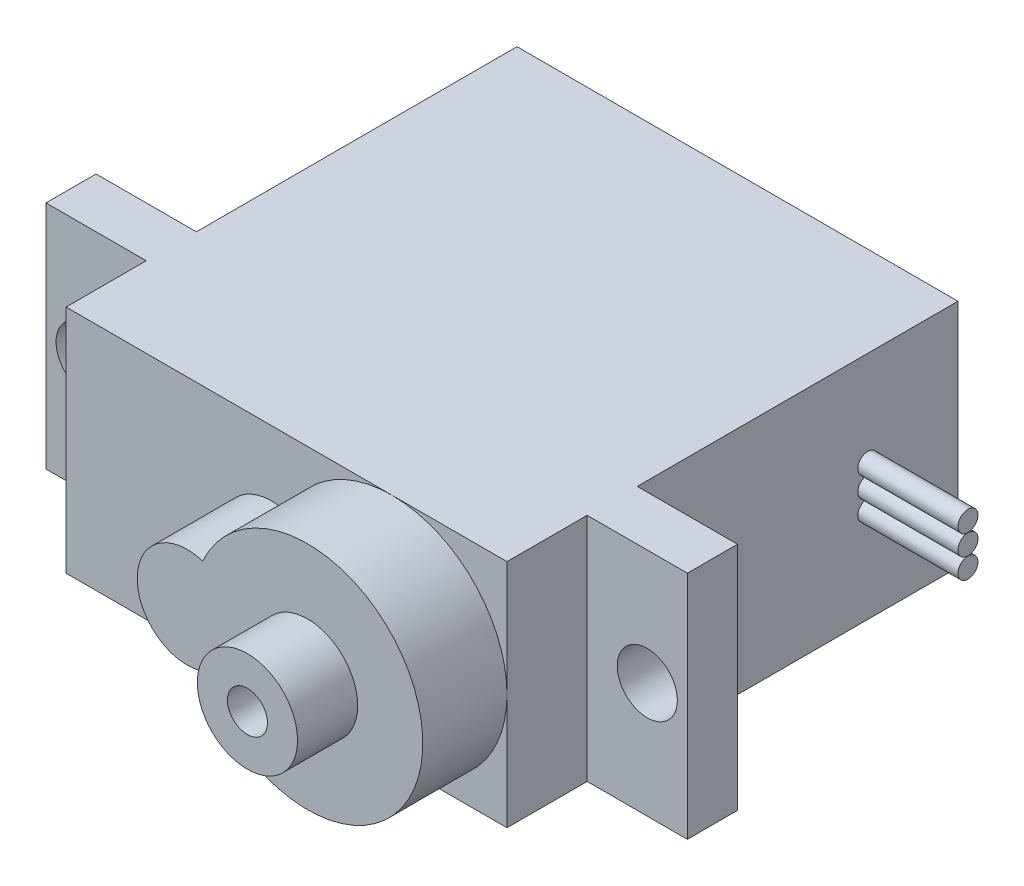
from build123d import *

# Parameters (mm, degrees)
SKETCH_1_W          = 22
SKETCH_1_H          = 11.5
EXTRUDE_1_DEPTH     = 16
SKETCH_2_W          = 32
SKETCH_2_H          = 11.5
EXTRUDE_2_DEPTH     = 2.5
SKETCH_3_W          = 22
SKETCH_3_H          = 11.5
EXTRUDE_3_DEPTH     = 4
EXTRUDE_4_DEPTH     = 4.2
SKETCH_5_R          = 1.5
CUT_EXTRUDE_1_DEPTH = 19.5
SKETCH_6_R          = 0.5
EXTRUDE_6_DEPTH     = 5
EXTRUDE_6_2_DEPTH   = 5
EXTRUDE_6_3_DEPTH   = 5
SKETCH_7_R          = 2.5
SKETCH_7_R_2        = 1
EXTRUDE_7_DEPTH     = 3
SKETCH_8_W          = 1.346153846
SKETCH_8_H          = 0.358974359
CUT_EXTRUDE_2_DEPTH = 2


with BuildPart() as part:
    # ｽｹｯﾁ1 → ﾎﾞｽ - 押し出し1 (new body)
    with BuildSketch(Plane.XY):
        with Locations((11, 5.75)):
            Rectangle(SKETCH_1_W, SKETCH_1_H)
    extrude(amount=EXTRUDE_1_DEPTH)

    # ｽｹｯﾁ2 → ﾎﾞｽ - 押し出し2 (add)
    with BuildSketch(Plane.XY.offset(16)):
        with Locations((11, 5.75)):
            Rectangle(SKETCH_2_W, SKETCH_2_H)
    extrude(amount=EXTRUDE_2_DEPTH)

    # ｽｹｯﾁ3 → ﾎﾞｽ - 押し出し3 (add)
    with BuildSketch(Plane.XY.offset(18.5)):
        with Locations((11, 5.75)):
            Rectangle(SKETCH_3_W, SKETCH_3_H)
    extrude(amount=EXTRUDE_3_DEPTH)

    # ｽｹｯﾁ4 → ﾎﾞｽ - 押し出し4 (add)
    with BuildSketch(Plane.XY.offset(22.5)):
        with BuildLine():
            ThreePointArc((11.015625, 8.129877803), (7.75, 5.75), (11.015625, 3.370122197))
            ThreePointArc((11.015625, 3.370122197), (22, 5.75), (11.015625, 8.129877803))
        make_face()
    extrude(amount=EXTRUDE_4_DEPTH)

    # ｽｹｯﾁ5 → ｶｯﾄ - 押し出し1 (cut, through all)
    with BuildSketch(Plane.XY.offset(18.5)):
        with Locations((-3, 5.75)):
            Circle(SKETCH_5_R)
        with Locations((25, 5.75)):
            Circle(SKETCH_5_R)
    extrude(amount=-CUT_EXTRUDE_1_DEPTH, mode=Mode.SUBTRACT)

    # ｽｹｯﾁ8 → ｶｯﾄ - 押し出し2 (cut)
    with BuildSketch(Plane.XZ):
        with BuildLine():
            Line((4.284609401, 12.059602692), (4.580482798, 12.236986506))
            add(Edge.make_bspline(
                [(4.580482798, 12.236986506), (4.608001035, 12.190922121), (4.660724916, 12.102664537), (4.748676275, 11.983406497), (4.839809186, 11.88204434), (4.93479852, 11.799167733), (5.033064468, 11.733918846), (5.135248522, 11.687716614), (5.241006332, 11.658900639), (5.312980154, 11.655400552), (5.348912285, 11.653653173)],
                knots=[0, 0, 0, 0, 0.000160901, 0.00030828, 0.000443778, 0.00056903, 0.000685513, 0.000796284, 0.00090427, 0.001011928, 0.001011928, 0.001011928, 0.001011928], degree=3))
            add(Edge.make_bspline(
                [(5.348912285, 11.653653173), (5.379599146, 11.654507845), (5.440435919, 11.656202236), (5.529998162, 11.672483038), (5.616979964, 11.697495167), (5.699588602, 11.733316098), (5.776684216, 11.776654584), (5.844290912, 11.829000761), (5.902737025, 11.887606967), (5.950546139, 11.952989622), (5.987226175, 12.02330677), (6.015418243, 12.095482722), (6.031063317, 12.17065129), (6.03342007, 12.221261753), (6.034609401, 12.246802211)],
                knots=[0, 0, 0, 0, 9.1978e-05, 0.000182347, 0.000272202, 0.000362975, 0.000451852, 0.000536835, 0.000618639, 0.000699414, 0.000778765, 0.000855983, 0.0009312, 0.001007828, 0.001007828, 0.001007828, 0.001007828], degree=3))
            add(Edge.make_bspline(
                [(6.034609401, 12.246802211), (6.03313509, 12.275943061), (6.030138032, 12.33518215), (6.004806552, 12.422581803), (5.964957305, 12.509074373), (5.928194661, 12.562575639), (5.909108599, 12.590351891)],
                knots=[0, 0, 0, 0, 8.7281e-05, 0.000177429, 0.000270909, 0.000371844, 0.000371844, 0.000371844, 0.000371844], degree=3))
            add(Edge.make_bspline(
                [(5.909108599, 12.590351891), (5.893437985, 12.610398715), (5.860539491, 12.652484513), (5.803981978, 12.715129749), (5.737615864, 12.779748168), (5.663712309, 12.848807224), (5.57957922, 12.919095021), (5.487851706, 12.993963299), (5.386187847, 13.070564876), (5.31488835, 13.121937442), (5.278098984, 13.14844484)],
                knots=[0, 0, 0, 0, 7.6319e-05, 0.000160223, 0.000252933, 0.000354147, 0.000463581, 0.000581729, 0.000709336, 0.000845369, 0.000845369, 0.000845369, 0.000845369], degree=3))
            add(Edge.make_bspline(
                [(5.278098984, 13.14844484), (5.241274988, 13.174673427), (5.170870311, 13.224820489), (5.072411729, 13.299244774), (4.984367266, 13.367288643), (4.907128249, 13.429592655), (4.840728653, 13.48616526), (4.784645242, 13.536463199), (4.740306684, 13.58184676), (4.715651104, 13.611288102), (4.704581356, 13.624506538)],
                knots=[0, 0, 0, 0, 0.000135623, 0.000259301, 0.000370234, 0.000469439, 0.00055697, 0.000631911, 0.000695377, 0.00074709, 0.00074709, 0.00074709, 0.00074709], degree=3))
            add(Edge.make_bspline(
                [(4.704581356, 13.624506538), (4.689108811, 13.645107575), (4.658679974, 13.685622279), (4.618513968, 13.748947137), (4.584374806, 13.813770402), (4.557612473, 13.880266267), (4.535076255, 13.947501196), (4.519918324, 14.016352441), (4.510426927, 14.08651106), (4.50945494, 14.13372456), (4.508968375, 14.157359102)],
                knots=[0, 0, 0, 0, 7.727e-05, 0.000151962, 0.000224716, 0.000296717, 0.00036678, 0.0004372, 0.000507902, 0.000578771, 0.000578771, 0.000578771, 0.000578771], degree=3))
            add(Edge.make_bspline(
                [(4.508968375, 14.157359102), (4.510273584, 14.194388877), (4.512856104, 14.267656941), (4.534696621, 14.374687771), (4.569169515, 14.476874188), (4.617464403, 14.573204522), (4.679721756, 14.661170503), (4.75176773, 14.74178399), (4.837579216, 14.809552572), (4.93173184, 14.868764631), (5.034788212, 14.915110556), (5.142779115, 14.950071536), (5.255876187, 14.969880794), (5.332479322, 14.972723559), (5.371348183, 14.974165993)],
                knots=[0, 0, 0, 0, 0.000110999, 0.000219625, 0.000326272, 0.00043382, 0.000541574, 0.000648775, 0.000756959, 0.000868438, 0.000981703, 0.00109501, 0.001208203, 0.0013248, 0.0013248, 0.0013248, 0.0013248], degree=3))
            add(Edge.make_bspline(
                [(5.371348183, 14.974165993), (5.412592283, 14.972743442), (5.494613635, 14.969914441), (5.61526285, 14.945316909), (5.731423567, 14.904616238), (5.824866832, 14.85842758), (5.897999593, 14.812296164), (5.953772326, 14.77027634), (6.010289777, 14.721901231), (6.068007831, 14.667041985), (6.125948491, 14.605195234), (6.184971943, 14.536784545), (6.245216212, 14.462227989), (6.283972072, 14.409003488), (6.30384017, 14.381718077)],
                knots=[0, 0, 0, 0, 0.000123638, 0.000245877, 0.000367608, 0.000492088, 0.000557638, 0.000626769, 0.000701372, 0.00078072, 0.000865532, 0.000955497, 0.001051745, 0.001152989, 0.001152989, 0.001152989, 0.001152989], degree=3))
            Line((6.30384017, 14.381718077), (6.019885843, 14.166473686))
            add(Edge.make_bspline(
                [(6.019885843, 14.166473686), (6.002739911, 14.188562376), (5.969720853, 14.231100029), (5.919591367, 14.290671345), (5.872342719, 14.345087825), (5.825792319, 14.392352953), (5.782398687, 14.435055086), (5.740281645, 14.471614843), (5.700047294, 14.502390438), (5.649330383, 14.535233998), (5.585612665, 14.567790502), (5.505628129, 14.59533958), (5.422041854, 14.611894642), (5.365112222, 14.614083529), (5.336292093, 14.615191635)],
                knots=[0, 0, 0, 0, 8.3877e-05, 0.000161528, 0.000233552, 0.000299993, 0.000360485, 0.000416152, 0.000467195, 0.000512312, 0.000597287, 0.000681099, 0.000765389, 0.000851809, 0.000851809, 0.000851809, 0.000851809], degree=3))
            add(Edge.make_bspline(
                [(5.336292093, 14.615191635), (5.300135571, 14.613979935), (5.230411123, 14.611643285), (5.131420887, 14.5861233), (5.042326962, 14.54594144), (4.965774397, 14.489626462), (4.90203742, 14.422905469), (4.855931961, 14.346126614), (4.828181797, 14.261344211), (4.824795517, 14.202202555), (4.823070939, 14.17208266)],
                knots=[0, 0, 0, 0, 0.000108248, 0.000208746, 0.00030443, 0.000399793, 0.000492054, 0.00057947, 0.000666386, 0.000756591, 0.000756591, 0.000756591, 0.000756591], degree=3))
            add(Edge.make_bspline(
                [(4.823070939, 14.17208266), (4.823464066, 14.153331182), (4.824250962, 14.115797562), (4.83522576, 14.06034614), (4.849325089, 14.005034801), (4.87166772, 13.950112218), (4.902513024, 13.894617859), (4.9430182, 13.837596121), (4.994031512, 13.778544413), (5.033108524, 13.740137039), (5.05374001, 13.719859102)],
                knots=[0, 0, 0, 0, 5.616e-05, 0.000112411, 0.000169046, 0.000227244, 0.000289691, 0.000359134, 0.000436702, 0.000523463, 0.000523463, 0.000523463, 0.000523463], degree=3))
            add(Edge.make_bspline(
                [(5.05374001, 13.719859102), (5.061401382, 13.713022077), (5.079603049, 13.696778868), (5.112878975, 13.670186588), (5.156821773, 13.637383815), (5.210283974, 13.596796499), (5.274251336, 13.549715037), (5.348730892, 13.496741425), (5.432892425, 13.436155966), (5.492614341, 13.393798425), (5.524192734, 13.37140157)],
                knots=[0, 0, 0, 0, 3.0802e-05, 7.3177e-05, 0.000127725, 0.000195314, 0.000274544, 0.000365991, 0.000469501, 0.000585644, 0.000585644, 0.000585644, 0.000585644], degree=3))
            add(Edge.make_bspline(
                [(5.524192734, 13.37140157), (5.562178647, 13.343760211), (5.635733104, 13.290236549), (5.740390684, 13.209820869), (5.835284492, 13.1311731), (5.920747695, 13.054795493), (5.997624604, 12.9812674), (6.065062324, 12.90970422), (6.123748005, 12.840618647), (6.186927223, 12.752046072), (6.251485043, 12.643264987), (6.30692655, 12.509986749), (6.341884898, 12.376190428), (6.346456413, 12.286263592), (6.348711965, 12.241894359)],
                knots=[0, 0, 0, 0, 0.000140932, 0.000272896, 0.000395881, 0.000510584, 0.000616697, 0.000714904, 0.000805482, 0.000888372, 0.001041088, 0.001183793, 0.001320341, 0.001453327, 0.001453327, 0.001453327, 0.001453327], degree=3))
            add(Edge.make_bspline(
                [(6.348711965, 12.241894359), (6.348054827, 12.210515994), (6.346753312, 12.14836861), (6.331792398, 12.057113533), (6.309872733, 11.968482664), (6.276835499, 11.883571551), (6.23651234, 11.800826789), (6.185346093, 11.722418888), (6.126038408, 11.64661249), (6.058004643, 11.575428998), (5.983558741, 11.510082802), (5.904875046, 11.451953741), (5.821824773, 11.403485417), (5.734858456, 11.363934575), (5.64395612, 11.333001058), (5.549148336, 11.310588189), (5.450278825, 11.296832478), (5.383078343, 11.295404716), (5.348912285, 11.294678814)],
                knots=[0, 0, 0, 0, 9.4044e-05, 0.000186263, 0.000276729, 0.000367488, 0.000459046, 0.000552398, 0.000647774, 0.000747454, 0.000847311, 0.000944634, 0.001040472, 0.001135227, 0.001230788, 0.001328063, 0.00142712, 0.00152957, 0.00152957, 0.00152957, 0.00152957], degree=3))
            add(Edge.make_bspline(
                [(5.348912285, 11.294678814), (5.322476942, 11.295189996), (5.269939182, 11.296205921), (5.1922297, 11.305187201), (5.116090111, 11.317894305), (5.042475829, 11.338068375), (4.970438418, 11.362545352), (4.900291183, 11.392683685), (4.832000129, 11.428800886), (4.765182546, 11.470095911), (4.700008372, 11.518153655), (4.637088904, 11.574127152), (4.574359718, 11.636472657), (4.513672322, 11.70688322), (4.453799178, 11.784221303), (4.395920768, 11.869210486), (4.33883905, 11.96138784), (4.303023583, 12.026252926), (4.284609401, 12.059602692)],
                knots=[0, 0, 0, 0, 7.9276e-05, 0.000157554, 0.000234438, 0.000310629, 0.000386236, 0.000462555, 0.000539392, 0.000617798, 0.000698008, 0.000781971, 0.000870217, 0.00096315, 0.001060616, 0.001163492, 0.001271478, 0.00138575, 0.00138575, 0.00138575, 0.00138575], degree=3))
        make_face()
        with BuildLine():
            Line((10.342301708, 14.287066635), (10.073070939, 14.031858301))
            add(Edge.make_bspline(
                [(10.073070939, 14.031858301), (10.024352051, 14.077689164), (9.928076005, 14.168258027), (9.771115762, 14.285769022), (9.607352128, 14.386435122), (9.437639631, 14.468341359), (9.266181077, 14.533694119), (9.095252301, 14.58022226), (8.926606599, 14.609894797), (8.814439381, 14.613443166), (8.759168696, 14.615191635)],
                knots=[0, 0, 0, 0, 0.000200536, 0.000396289, 0.000586999, 0.000776397, 0.000960787, 0.001136655, 0.001307246, 0.001472961, 0.001472961, 0.001472961, 0.001472961], degree=3))
            add(Edge.make_bspline(
                [(8.759168696, 14.615191635), (8.725253996, 14.614778029), (8.657512555, 14.61395189), (8.556890611, 14.603407674), (8.457323974, 14.58824281), (8.359000599, 14.566300933), (8.261729313, 14.538491873), (8.165848421, 14.50370641), (8.071179066, 14.463151166), (7.978612985, 14.416288692), (7.888872481, 14.364808845), (7.804115646, 14.307760305), (7.723802247, 14.246971515), (7.649441821, 14.180920535), (7.580606635, 14.11020567), (7.515658263, 14.036142364), (7.456880967, 13.956707145), (7.403789802, 13.873361519), (7.356428184, 13.78756933), (7.31461953, 13.70015634), (7.279522442, 13.611412486), (7.251752987, 13.521226408), (7.228842333, 13.430295818), (7.212724726, 13.337991098), (7.203638003, 13.244213413), (7.202066223, 13.181416154), (7.201276067, 13.149847083)],
                knots=[0, 0, 0, 0, 0.000101701, 0.000203139, 0.000303193, 0.000403728, 0.000505139, 0.000606491, 0.000709509, 0.000813922, 0.000917583, 0.001019673, 0.001120217, 0.001219549, 0.001317716, 0.001416124, 0.001514842, 0.00161384, 0.001712379, 0.001808658, 0.001904353, 0.001998376, 0.002091562, 0.002185504, 0.002279198, 0.002373914, 0.002373914, 0.002373914, 0.002373914], degree=3))
            add(Edge.make_bspline(
                [(7.201276067, 13.149847083), (7.202031786, 13.117576266), (7.203541159, 13.053122752), (7.213201478, 12.95692868), (7.231129719, 12.862163277), (7.255097427, 12.768515144), (7.285078243, 12.675823896), (7.322450909, 12.584491387), (7.36671651, 12.494520995), (7.417953062, 12.406723378), (7.474139265, 12.321200355), (7.537082346, 12.240640833), (7.60394293, 12.163972056), (7.677156829, 12.092896292), (7.754376372, 12.025512396), (7.837908648, 11.963676874), (7.926111108, 11.906198651), (8.01911832, 11.853802131), (8.115921103, 11.806993596), (8.215177856, 11.7653697), (8.317205671, 11.731090362), (8.421468361, 11.703152258), (8.527841633, 11.680251961), (8.636865435, 11.665519481), (8.747738144, 11.65482865), (8.822476776, 11.65404698), (8.860130234, 11.653653173)],
                knots=[0, 0, 0, 0, 9.6818e-05, 0.000193372, 0.000289633, 0.000385881, 0.000483216, 0.000581645, 0.00068167, 0.000783767, 0.00088644, 0.000988395, 0.001090231, 0.001191373, 0.001294266, 0.001397472, 0.001502873, 0.001609927, 0.001717482, 0.001825293, 0.001932604, 0.002040093, 0.002149, 0.002258763, 0.002369974, 0.002482889, 0.002482889, 0.002482889, 0.002482889], degree=3))
            add(Edge.make_bspline(
                [(8.860130234, 11.653653173), (8.905508581, 11.654601749), (8.994616339, 11.656464433), (9.125602781, 11.670964722), (9.251405852, 11.693611516), (9.371672055, 11.726777413), (9.486541076, 11.769081088), (9.596434017, 11.820076474), (9.700485676, 11.881719533), (9.799008849, 11.9512934), (9.889766035, 12.028808233), (9.971620159, 12.112452688), (10.043265648, 12.201820755), (10.105770348, 12.29638607), (10.157479002, 12.396931375), (10.199921797, 12.502963937), (10.232455089, 12.614531449), (10.245810063, 12.691623081), (10.252558119, 12.73057625)],
                knots=[0, 0, 0, 0, 0.000136106, 0.000267267, 0.000394882, 0.00051922, 0.000641, 0.000761758, 0.000882124, 0.001003321, 0.001123172, 0.001239687, 0.001353892, 0.00146629, 0.00157918, 0.001692449, 0.001808499, 0.001927028, 0.001927028, 0.001927028, 0.001927028], degree=3))
            Line((10.252558119, 12.73057625), (9.085891452, 12.73057625))
            Line((9.085891452, 12.73057625), (9.085891452, 13.089550609))
            Line((9.085891452, 13.089550609), (10.566660683, 13.089550609))
            add(Edge.make_bspline(
                [(10.566660683, 13.089550609), (10.564954834, 13.02264312), (10.561616181, 12.891693078), (10.538197265, 12.700722807), (10.500380753, 12.520351114), (10.448720441, 12.350388042), (10.381845161, 12.19107445), (10.300472632, 12.042248584), (10.203300511, 11.904871903), (10.09379007, 11.777822899), (9.970890112, 11.664493687), (9.837921492, 11.564887749), (9.694664524, 11.480985134), (9.541254716, 11.412724471), (9.378194283, 11.359450476), (9.205105903, 11.3216789), (9.022224302, 11.299048936), (8.896887625, 11.296157557), (8.832786484, 11.294678814)],
                knots=[0, 0, 0, 0, 0.000200697, 0.000392801, 0.000576238, 0.000752994, 0.000924878, 0.001093697, 0.001260784, 0.001428776, 0.001595974, 0.001761299, 0.001926279, 0.002092931, 0.002264096, 0.002439994, 0.002623661, 0.002815923, 0.002815923, 0.002815923, 0.002815923], degree=3))
            add(Edge.make_bspline(
                [(8.832786484, 11.294678814), (8.793276349, 11.295247935), (8.715349628, 11.296370426), (8.6002587, 11.304347773), (8.488341079, 11.316628349), (8.37961307, 11.335173473), (8.273674728, 11.357888127), (8.171055143, 11.386974846), (8.071363401, 11.420643545), (7.974445416, 11.458939219), (7.881180869, 11.503310875), (7.791154352, 11.552620515), (7.703868226, 11.606613876), (7.619917061, 11.666224721), (7.53886344, 11.731007181), (7.461229996, 11.8010911), (7.386582118, 11.87626222), (7.339821654, 11.92964123), (7.316260042, 11.956537788)],
                knots=[0, 0, 0, 0, 0.000118523, 0.000233765, 0.000345956, 0.000456148, 0.000564516, 0.000670839, 0.000775933, 0.000880089, 0.000983271, 0.001085557, 0.001187895, 0.001290998, 0.001394253, 0.001499002, 0.001604602, 0.001711853, 0.001711853, 0.001711853, 0.001711853], degree=3))
            add(Edge.make_bspline(
                [(7.316260042, 11.956537788), (7.28207411, 11.999208441), (7.214269697, 12.083841459), (7.126991541, 12.219441403), (7.052590138, 12.359843263), (6.992222316, 12.505437891), (6.945084229, 12.656089104), (6.911277976, 12.811604396), (6.891470687, 12.972184026), (6.88861715, 13.080849291), (6.887173503, 13.135824647)],
                knots=[0, 0, 0, 0, 0.00016394, 0.000325158, 0.000482912, 0.000640071, 0.000797293, 0.000955853, 0.00111691, 0.001281823, 0.001281823, 0.001281823, 0.001281823], degree=3))
            add(Edge.make_bspline(
                [(6.887173503, 13.135824647), (6.887705741, 13.1769909), (6.888763453, 13.258800207), (6.901588969, 13.380257515), (6.919990387, 13.499558207), (6.947037442, 13.616604763), (6.981133707, 13.731475355), (7.023687193, 13.844223319), (7.073232089, 13.954915191), (7.130817585, 14.062789059), (7.194902044, 14.166413471), (7.264452265, 14.265371275), (7.340455865, 14.35786034), (7.421671664, 14.445051988), (7.509068655, 14.525850835), (7.601828078, 14.601004946), (7.700021421, 14.670615131), (7.803957601, 14.733584966), (7.912085286, 14.790148587), (8.024145287, 14.839737798), (8.140103398, 14.880721114), (8.259090876, 14.915494893), (8.382008376, 14.941210034), (8.507963913, 14.959858779), (8.637614025, 14.972619379), (8.725250054, 14.973645635), (8.769685523, 14.974165993)],
                knots=[0, 0, 0, 0, 0.000123447, 0.000245326, 0.00036601, 0.000485407, 0.000605413, 0.000725221, 0.000846669, 0.000968994, 0.001091771, 0.00121199, 0.001331568, 0.001450618, 0.001569191, 0.001688326, 0.001808545, 0.001929991, 0.002052609, 0.002174413, 0.002297271, 0.002421315, 0.002546037, 0.002673651, 0.002803207, 0.002936466, 0.002936466, 0.002936466, 0.002936466], degree=3))
            add(Edge.make_bspline(
                [(8.769685523, 14.974165993), (8.805923766, 14.973586502), (8.877779945, 14.972437438), (8.984705677, 14.96447279), (9.089978692, 14.951848909), (9.193755082, 14.934622122), (9.295681448, 14.911158431), (9.396048153, 14.883080147), (9.49500069, 14.850388324), (9.592228939, 14.811399478), (9.688386655, 14.767145853), (9.784008495, 14.717332431), (9.878767741, 14.661107426), (9.972828723, 14.59830389), (10.066784581, 14.530000473), (10.159149223, 14.454243649), (10.252152167, 14.374020893), (10.311953981, 14.316338709), (10.342301708, 14.287066635)],
                knots=[0, 0, 0, 0, 0.00010871, 0.000215559, 0.000321482, 0.000426718, 0.00053098, 0.000635089, 0.000739295, 0.000843451, 0.000949174, 0.001056739, 0.001166761, 0.001279546, 0.001395941, 0.001515076, 0.00163782, 0.001764288, 0.001764288, 0.001764288, 0.001764288], degree=3))
        make_face()
        with Locations((11.64358376, 12.73057625)):
            Rectangle(SKETCH_8_W, SKETCH_8_H)
        with BuildLine():
            Line((13.348711965, 11.294678814), (13.097710362, 11.469258141))
            Line((13.097710362, 11.469258141), (14.070867414, 12.891834263))
            add(Edge.make_bspline(
                [(14.070867414, 12.891834263), (14.008776678, 12.884241199), (13.886516558, 12.869290034), (13.763379456, 12.86654338), (13.702778471, 12.865191635)],
                knots=[0, 0, 0, 0, 0.000187529, 0.000369255, 0.000369255, 0.000369255, 0.000369255], degree=3))
            add(Edge.make_bspline(
                [(13.702778471, 12.865191635), (13.666036423, 12.866132711), (13.593914997, 12.867979962), (13.487883344, 12.88262177), (13.385997783, 12.905171898), (13.288528428, 12.938820653), (13.195108923, 12.980638862), (13.105943209, 13.032495876), (13.021151319, 13.093502167), (12.941643909, 13.163335159), (12.86933217, 13.240013211), (12.804908872, 13.321168854), (12.75136774, 13.407744825), (12.706891155, 13.497975044), (12.673160701, 13.593156395), (12.648598164, 13.692205795), (12.633475809, 13.795817437), (12.631676714, 13.866342568), (12.630763247, 13.902150769)],
                knots=[0, 0, 0, 0, 0.000110185, 0.000216284, 0.000320547, 0.000422759, 0.000525058, 0.000627155, 0.000731643, 0.000837964, 0.0009441, 0.00104747, 0.001148247, 0.001248901, 0.001348697, 0.001450555, 0.001554666, 0.00166205, 0.00166205, 0.00166205, 0.00166205], degree=3))
            add(Edge.make_bspline(
                [(12.630763247, 13.902150769), (12.632497682, 13.951119422), (12.635902025, 14.047234953), (12.663300543, 14.187668722), (12.708360882, 14.320455266), (12.771189259, 14.44524546), (12.85032398, 14.560244199), (12.94543257, 14.663852808), (13.055936534, 14.754597662), (13.179318554, 14.83260174), (13.312671574, 14.895336737), (13.452340232, 14.941576037), (13.597254352, 14.968774785), (13.695422023, 14.972360646), (13.744845779, 14.974165993)],
                knots=[0, 0, 0, 0, 0.000146818, 0.000288173, 0.000427413, 0.000566316, 0.000705952, 0.000844895, 0.000986821, 0.001133677, 0.001281714, 0.001427825, 0.001574003, 0.00172222, 0.00172222, 0.00172222, 0.00172222], degree=3))
            add(Edge.make_bspline(
                [(13.744845779, 14.974165993), (13.793334199, 14.97233583), (13.889142745, 14.968719601), (14.030031752, 14.942235632), (14.164972769, 14.897598959), (14.293217756, 14.835914395), (14.411957168, 14.758593487), (14.518732979, 14.666458964), (14.611108518, 14.559453436), (14.688932399, 14.440164946), (14.751402439, 14.311997965), (14.796474722, 14.178214043), (14.824220361, 14.039775321), (14.827716688, 13.945980847), (14.829481196, 13.89864516)],
                knots=[0, 0, 0, 0, 0.000145418, 0.000287333, 0.000428343, 0.000570713, 0.000713061, 0.00085223, 0.000992387, 0.001135706, 0.001278381, 0.001418948, 0.001558239, 0.001700158, 0.001700158, 0.001700158, 0.001700158], degree=3))
            add(Edge.make_bspline(
                [(14.829481196, 13.89864516), (14.828302787, 13.861901393), (14.825912679, 13.787375852), (14.809176372, 13.674145509), (14.780756187, 13.55869428), (14.748504488, 13.460972684), (14.71737232, 13.380264235), (14.688071189, 13.316512655), (14.655559035, 13.249411391), (14.61764027, 13.179664053), (14.576877973, 13.106381518), (14.530818696, 13.030298803), (14.480513124, 12.951313809), (14.444683405, 12.898066721), (14.426336164, 12.870800609)],
                knots=[0, 0, 0, 0, 0.000110219, 0.000223552, 0.000342587, 0.000466527, 0.000532018, 0.000601997, 0.000676938, 0.00075567, 0.000840114, 0.000928491, 0.001022434, 0.001121023, 0.001121023, 0.001121023, 0.001121023], degree=3))
            Line((14.426336164, 12.870800609), (13.348711965, 11.294678814))
        make_face()
        with BuildLine():
            add(Edge.make_bspline(
                [(13.76097158, 13.224165993), (13.788805594, 13.224926377), (13.842988957, 13.226406586), (13.922366256, 13.235415828), (13.99729046, 13.251389814), (14.067961709, 13.274309526), (14.135088611, 13.301966195), (14.197604939, 13.337178181), (14.255563014, 13.379194816), (14.309350942, 13.426404832), (14.357114941, 13.478855415), (14.399657972, 13.533752522), (14.435818539, 13.591337132), (14.464381816, 13.652330394), (14.487866392, 13.715247603), (14.504084404, 13.781101958), (14.513068737, 13.849550358), (14.514600312, 13.896049016), (14.515378631, 13.919678814)],
                knots=[0, 0, 0, 0, 8.3507e-05, 0.00016256, 0.000239294, 0.000312908, 0.000385178, 0.000456751, 0.000527578, 0.000599603, 0.000671055, 0.000740051, 0.000807755, 0.000874553, 0.000941763, 0.001008931, 0.001077548, 0.001148448, 0.001148448, 0.001148448, 0.001148448], degree=3))
            add(Edge.make_bspline(
                [(14.515378631, 13.919678814), (14.514708962, 13.943318479), (14.513389297, 13.989903339), (14.502801997, 14.058453079), (14.484176774, 14.12414634), (14.45918629, 14.18734277), (14.426266052, 14.247523142), (14.386762566, 14.305443014), (14.339830116, 14.360735141), (14.28582755, 14.412099125), (14.227592997, 14.459447024), (14.165532497, 14.5012331), (14.100157581, 14.536254296), (14.031867091, 14.565153266), (13.960518742, 14.587705042), (13.886154754, 14.603922407), (13.808399348, 14.612894161), (13.755618062, 14.614416056), (13.728719978, 14.615191635)],
                knots=[0, 0, 0, 0, 7.09e-05, 0.000139717, 0.000207422, 0.000275384, 0.000343146, 0.000412766, 0.000485392, 0.000560268, 0.000636041, 0.000710323, 0.000784354, 0.000858188, 0.000932471, 0.001008519, 0.001086179, 0.001166885, 0.001166885, 0.001166885, 0.001166885], degree=3))
            add(Edge.make_bspline(
                [(13.728719978, 14.615191635), (13.702055824, 14.614414803), (13.649740975, 14.612890665), (13.572676816, 14.60393946), (13.498815648, 14.587595976), (13.427674027, 14.565163712), (13.359385567, 14.536252141), (13.294013734, 14.501231265), (13.231938717, 14.459456643), (13.173759997, 14.41206187), (13.119662075, 14.360974224), (13.073536546, 14.305200795), (13.033942653, 14.247553271), (13.001067651, 14.187334763), (12.976065133, 14.124148477), (12.957443132, 14.0584525), (12.946854966, 13.98990349), (12.94553542, 13.94331853), (12.944865811, 13.919678814)],
                knots=[0, 0, 0, 0, 8.0005e-05, 0.000156969, 0.000232332, 0.000306614, 0.000380449, 0.000454479, 0.000528762, 0.000604535, 0.000679411, 0.000751586, 0.000821205, 0.000888968, 0.00095693, 0.001024634, 0.001093451, 0.001164351, 0.001164351, 0.001164351, 0.001164351], degree=3))
            add(Edge.make_bspline(
                [(12.944865811, 13.919678814), (12.945471737, 13.896030615), (12.946666734, 13.849392039), (12.958194524, 13.780865646), (12.977472804, 13.715177452), (13.003292194, 13.651688745), (13.037293785, 13.591016887), (13.079017633, 13.533449525), (13.127923179, 13.478334075), (13.183356666, 13.426526863), (13.244024827, 13.378974688), (13.308821573, 13.337444306), (13.37663141, 13.302371861), (13.447693041, 13.274230477), (13.521479841, 13.251618814), (13.598654972, 13.235445268), (13.67896321, 13.226493002), (13.733373192, 13.224949105), (13.76097158, 13.224165993)],
                knots=[0, 0, 0, 0, 7.09e-05, 0.000139828, 0.000207725, 0.00027595, 0.000345002, 0.000415829, 0.000488844, 0.000565728, 0.000643147, 0.000719775, 0.000796287, 0.0008718, 0.000948761, 0.001027552, 0.001107998, 0.001190805, 0.001190805, 0.001190805, 0.001190805], degree=3))
        make_face(mode=Mode.SUBTRACT)
        with BuildLine():
            add(Edge.make_bspline(
                [(15.278199144, 13.13302016), (15.278527162, 13.189117548), (15.279164342, 13.298087532), (15.286252763, 13.456872174), (15.298028106, 13.605832463), (15.314165479, 13.744975529), (15.333803459, 13.874337294), (15.360018945, 13.993572051), (15.389831748, 14.103231657), (15.424384194, 14.203673706), (15.463371983, 14.296251409), (15.505806244, 14.38267661), (15.553371038, 14.462818543), (15.603347951, 14.537956333), (15.657760023, 14.606860028), (15.715058813, 14.67050269), (15.777480689, 14.727413441), (15.842903698, 14.779259743), (15.911920162, 14.824709215), (15.982562828, 14.864741953), (16.055317934, 14.898941821), (16.130384117, 14.925832257), (16.207086675, 14.948043103), (16.285693741, 14.963232051), (16.366335105, 14.97278896), (16.42076654, 14.973702627), (16.44837142, 14.974165993)],
                knots=[0, 0, 0, 0, 0.000168282, 0.000326891, 0.000476705, 0.00061646, 0.000747059, 0.00086904, 0.000982494, 0.001087814, 0.001187428, 0.001283689, 0.001376399, 0.001466822, 0.001554203, 0.001639568, 0.001723424, 0.001807301, 0.001889751, 0.001971063, 0.002050735, 0.002130583, 0.002210036, 0.002290062, 0.002370508, 0.002453288, 0.002453288, 0.002453288, 0.002453288], degree=3))
            add(Edge.make_bspline(
                [(16.44837142, 14.974165993), (16.476206898, 14.973678178), (16.531562907, 14.972708067), (16.613403283, 14.963384125), (16.693352964, 14.947913002), (16.771071103, 14.925992027), (16.847196089, 14.898796351), (16.921132497, 14.864709233), (16.993339579, 14.825030366), (17.062669866, 14.778406489), (17.129884482, 14.726424213), (17.193332445, 14.667661544), (17.25301953, 14.602711824), (17.309694836, 14.532269961), (17.361750433, 14.454984876), (17.411323865, 14.372200766), (17.455695901, 14.282469901), (17.498430576, 14.187289433), (17.535317563, 14.084025775), (17.568583808, 13.973261014), (17.595462777, 13.853686827), (17.617852049, 13.725930582), (17.635196945, 13.589523099), (17.647829587, 13.444756783), (17.654502672, 13.291536392), (17.655759374, 13.186778543), (17.656404273, 13.13302016)],
                knots=[0, 0, 0, 0, 8.3481e-05, 0.000166017, 0.000246731, 0.000327534, 0.000408041, 0.000488986, 0.000571522, 0.000654944, 0.000739373, 0.000826202, 0.000914021, 0.001003809, 0.001097153, 0.001193347, 0.001293057, 0.001397277, 0.001506176, 0.001621751, 0.001744038, 0.001873599, 0.002010742, 0.002156422, 0.002309427, 0.002470709, 0.002470709, 0.002470709, 0.002470709], degree=3))
            add(Edge.make_bspline(
                [(17.656404273, 13.13302016), (17.655752688, 13.079496252), (17.654483102, 12.9752071), (17.647904395, 12.822676125), (17.634945764, 12.678678082), (17.618735776, 12.542867619), (17.596284813, 12.41581), (17.568679647, 12.297065552), (17.538029324, 12.18612148), (17.50019453, 12.083886669), (17.458783819, 11.988934946), (17.413728623, 11.900267797), (17.365458797, 11.817101505), (17.312870052, 11.740101758), (17.256816639, 11.668723101), (17.19609885, 11.604225478), (17.132428265, 11.545054806), (17.065015849, 11.492403179), (16.994604298, 11.446318374), (16.922645221, 11.405104524), (16.847861838, 11.371871829), (16.771948885, 11.343336788), (16.693820519, 11.321536336), (16.613574128, 11.30646248), (16.531617892, 11.295890632), (16.476216327, 11.295084152), (16.44837142, 11.294678814)],
                knots=[0, 0, 0, 0, 0.000160581, 0.000312886, 0.000457868, 0.000594226, 0.000723097, 0.000844701, 0.000959884, 0.001068125, 0.001171421, 0.001270505, 0.001366343, 0.001459687, 0.001550023, 0.00163832, 0.001725149, 0.001810562, 0.001894568, 0.001977446, 0.00205903, 0.002139777, 0.00222058, 0.002301983, 0.002384599, 0.00246808, 0.00246808, 0.00246808, 0.00246808], degree=3))
            add(Edge.make_bspline(
                [(16.44837142, 11.294678814), (16.420767306, 11.295145169), (16.366337381, 11.296064731), (16.285684956, 11.305578463), (16.207402512, 11.320873966), (16.131103758, 11.34229057), (16.056397243, 11.368505406), (15.984300957, 11.40265909), (15.914013273, 11.441993159), (15.845721717, 11.48678858), (15.780709556, 11.538110264), (15.71861095, 11.594874552), (15.660985931, 11.658497964), (15.607351836, 11.727975887), (15.556377748, 11.802669129), (15.509488374, 11.883597502), (15.46611752, 11.970440113), (15.42647403, 12.063758023), (15.391325366, 12.164912951), (15.360277658, 12.27506213), (15.3357635, 12.395177766), (15.314780545, 12.524295133), (15.297856162, 12.662969063), (15.286301837, 12.811274841), (15.279160522, 12.96912005), (15.278525451, 13.077389825), (15.278199144, 13.13302016)],
                knots=[0, 0, 0, 0, 8.278e-05, 0.000163226, 0.000243252, 0.00032184, 0.00040079, 0.000480463, 0.00056082, 0.000642298, 0.000725191, 0.000809047, 0.000894412, 0.000982346, 0.001072188, 0.001165503, 0.001262704, 0.001363236, 0.001469448, 0.001583766, 0.001706286, 0.001836995, 0.001976138, 0.002125253, 0.002283161, 0.002450041, 0.002450041, 0.002450041, 0.002450041], degree=3))
        make_face()
        with BuildLine():
            add(Edge.make_bspline(
                [(15.592301708, 13.134422404), (15.592421155, 13.087673705), (15.592652979, 12.99694366), (15.598709179, 12.865100399), (15.606959411, 12.74213007), (15.617600709, 12.627876534), (15.633403657, 12.522726521), (15.651110445, 12.425956838), (15.672658535, 12.338079601), (15.698153552, 12.25849179), (15.727192649, 12.185842722), (15.758898513, 12.118241507), (15.792959236, 12.05488957), (15.831078386, 11.996355962), (15.87259345, 11.942449798), (15.916566709, 11.892216966), (15.964639293, 11.847419984), (16.031143036, 11.793693129), (16.11893951, 11.738173996), (16.229559965, 11.689827906), (16.343228416, 11.659445449), (16.420379666, 11.655581693), (16.458888247, 11.653653173)],
                knots=[0, 0, 0, 0, 0.000140231, 0.000272162, 0.000395845, 0.00050998, 0.000616273, 0.00071473, 0.000805025, 0.000887508, 0.000965234, 0.00103957, 0.001111417, 0.001180842, 0.001248855, 0.001315406, 0.001380877, 0.0014457, 0.001571746, 0.00169106, 0.001806864, 0.001922266, 0.001922266, 0.001922266, 0.001922266], degree=3))
            add(Edge.make_bspline(
                [(16.458888247, 11.653653173), (16.497645919, 11.655250954), (16.575081242, 11.658443217), (16.688215037, 11.689241954), (16.798045307, 11.735711493), (16.884117247, 11.790658999), (16.949599791, 11.842987328), (16.996516781, 11.887601977), (17.039578829, 11.937557844), (17.080420904, 11.99145714), (17.11787998, 12.050329624), (17.151943117, 12.113892199), (17.183026465, 12.182321377), (17.200735511, 12.230091116), (17.209789689, 12.254514551)],
                knots=[0, 0, 0, 0, 0.000116044, 0.000231848, 0.000349318, 0.000472837, 0.000536674, 0.000600645, 0.000666733, 0.000734322, 0.000803367, 0.000875831, 0.000950509, 0.001028633, 0.001028633, 0.001028633, 0.001028633], degree=3))
            add(Edge.make_bspline(
                [(17.209789689, 12.254514551), (17.220341457, 12.285744291), (17.241766071, 12.349154055), (17.269377845, 12.447517707), (17.291123244, 12.550720471), (17.31068661, 12.658145588), (17.324039666, 12.770585289), (17.334787479, 12.887691673), (17.341118166, 13.009553035), (17.341902917, 13.092348026), (17.342301708, 13.134422404)],
                knots=[0, 0, 0, 0, 9.8886e-05, 0.00020078, 0.000306259, 0.000415188, 0.00052824, 0.000645799, 0.000767957, 0.000894177, 0.000894177, 0.000894177, 0.000894177], degree=3))
            add(Edge.make_bspline(
                [(17.342301708, 13.134422404), (17.341751519, 13.176489976), (17.340675231, 13.258783141), (17.336561244, 13.379301322), (17.325937669, 13.493769083), (17.31413855, 13.602679555), (17.296741329, 13.705429858), (17.277983522, 13.802880163), (17.25278231, 13.893823188), (17.225862535, 13.97968277), (17.19505214, 14.059483424), (17.161136405, 14.133597211), (17.124914647, 14.202381935), (17.085572406, 14.265648877), (17.043576723, 14.32368142), (16.997819174, 14.375316014), (16.950114801, 14.422152983), (16.883297615, 14.475615552), (16.795823325, 14.530127247), (16.686977678, 14.580293007), (16.573707034, 14.6091013), (16.49713358, 14.613162987), (16.458888247, 14.615191635)],
                knots=[0, 0, 0, 0, 0.000126219, 0.000246912, 0.000361616, 0.00047102, 0.00057545, 0.000674176, 0.000768567, 0.000858368, 0.000944043, 0.001024988, 0.001102772, 0.001177091, 0.00124833, 0.001317386, 0.001383826, 0.001448649, 0.001573728, 0.001692043, 0.001806995, 0.001921698, 0.001921698, 0.001921698, 0.001921698], degree=3))
            add(Edge.make_bspline(
                [(16.458888247, 14.615191635), (16.420177655, 14.613160188), (16.342685949, 14.609093594), (16.228237994, 14.58040034), (16.118533643, 14.530387374), (16.031290668, 14.475435002), (15.964426882, 14.42309669), (15.917344188, 14.377710236), (15.873198016, 14.328063982), (15.832530316, 14.273662067), (15.794441033, 14.2151967), (15.75946002, 14.152207935), (15.72794269, 14.084376571), (15.698858154, 14.011760135), (15.673285366, 13.932179191), (15.652191403, 13.844410197), (15.63270435, 13.747948306), (15.618909081, 13.642228798), (15.606645325, 13.527946644), (15.598763977, 13.404669326), (15.59263272, 13.272604946), (15.592414255, 13.181405787), (15.592301708, 13.134422404)],
                knots=[0, 0, 0, 0, 0.000116101, 0.000232413, 0.000351368, 0.000476447, 0.000540832, 0.000605795, 0.000672346, 0.000739935, 0.00080936, 0.000881545, 0.00095588, 0.001033607, 0.001116089, 0.001206384, 0.001304286, 0.001411174, 0.001526077, 0.001649061, 0.001781692, 0.001922624, 0.001922624, 0.001922624, 0.001922624], degree=3))
        make_face(mode=Mode.SUBTRACT)
    extrude(amount=-CUT_EXTRUDE_2_DEPTH, mode=Mode.SUBTRACT)


with BuildPart() as body_2:
    # ｽｹｯﾁ6 → ﾎﾞｽ - 押し出し6 (new body)
    with BuildSketch(Plane(origin=(22, 0, 0), x_dir=(0, 0, -1), z_dir=(1, 0, 0))):
        with Locations((-4.5, 5.75)):
            Circle(SKETCH_6_R)
    extrude(amount=EXTRUDE_6_DEPTH)


with BuildPart() as body_3:
    # ｽｹｯﾁ6 → Extrude 6 2 (new body)
    with BuildSketch(Plane(origin=(22, 0, 0), x_dir=(0, 0, -1), z_dir=(1, 0, 0))):
        with Locations((-4.5, 6.76)):
            Circle(SKETCH_6_R)
    extrude(amount=EXTRUDE_6_2_DEPTH)


with BuildPart() as body_4:
    # ｽｹｯﾁ6 → Extrude 6 3 (new body)
    with BuildSketch(Plane(origin=(22, 0, 0), x_dir=(0, 0, -1), z_dir=(1, 0, 0))):
        with Locations((-4.5, 4.74)):
            Circle(SKETCH_6_R)
    extrude(amount=EXTRUDE_6_3_DEPTH)


with BuildPart() as body_5:
    # ｽｹｯﾁ7 → ﾎﾞｽ - 押し出し7 (new body)
    with BuildSketch(Plane.XY.offset(26.7)):
        with Locations((16.25, 5.75)):
            Circle(SKETCH_7_R)
        with Locations((16.25, 5.75)):
            Circle(SKETCH_7_R_2, mode=Mode.SUBTRACT)
    extrude(amount=EXTRUDE_7_DEPTH)


solid = Compound([part.part, body_2.part, body_3.part, body_4.part, body_5.part])
